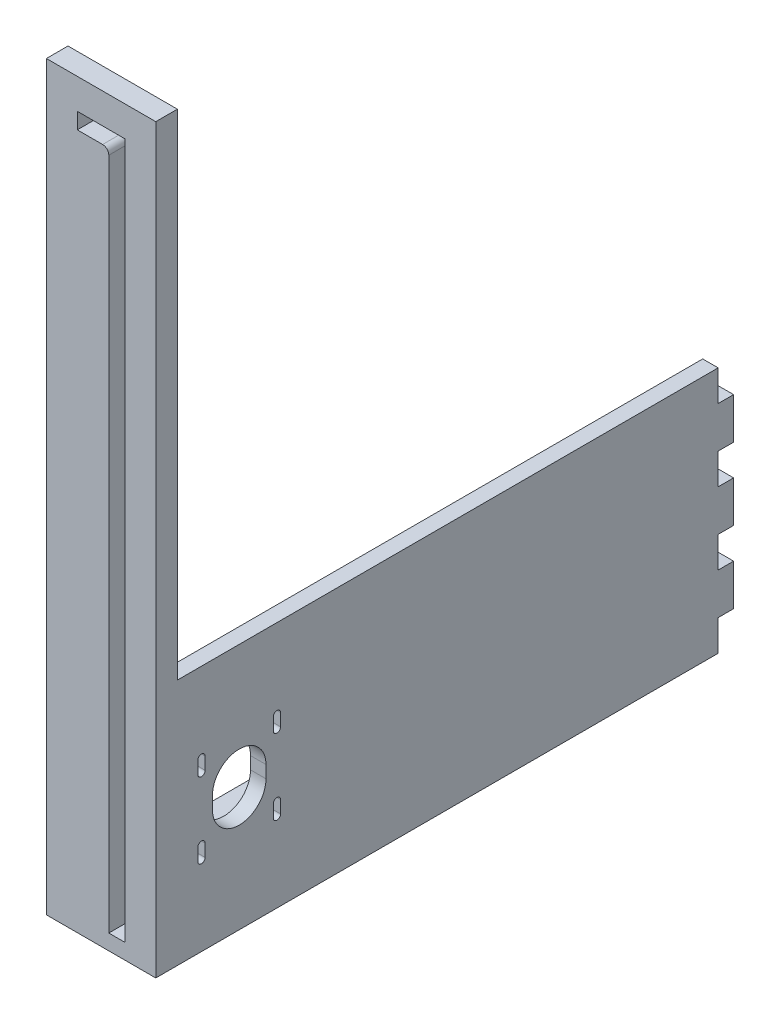
from build123d import *

# Parameters (mm, degrees)
SKETCH1_W           = 44.958
SKETCH1_H           = 304.8
BOSS_EXTRUDE1_DEPTH = 8.89
SKETCH2_W           = 8.89
SKETCH2_H           = 101.6
BOSS_EXTRUDE2_DEPTH = 6.35
SKETCH3_W           = 222.25
SKETCH3_H           = 6.35
BOSS_EXTRUDE3_DEPTH = 38.608


with BuildPart() as part:
    # Sketch1 → Boss-Extrude1 (new body)
    with BuildSketch(Plane.XY):
        with Locations((-6.477, 3.048)):
            Rectangle(SKETCH1_W, SKETCH1_H)
        with BuildLine():
            Line((-3.302, 133.858), (-3.302, -143.002))
            Line((-3.302, -143.002), (3.302, -143.002))
            Line((3.302, -143.002), (3.302, 143.002))
            Line((3.302, 143.002), (-16.256, 143.002))
            Line((-16.256, 143.002), (-16.256, 136.398))
            Line((-16.256, 136.398), (-5.842, 136.398))
            ThreePointArc((-5.842, 136.398), (-4.045948776, 135.654051224), (-3.302, 133.858))
        make_face(mode=Mode.SUBTRACT)
    extrude(amount=BOSS_EXTRUDE1_DEPTH)

    # Sketch2 → Boss-Extrude2 (add)
    with BuildSketch(Plane(origin=(16.002, 0, 0), x_dir=(0, 0, -1), z_dir=(1, 0, 0))):
        Polygon((222.25, -60.452), (222.25, -47.752), (0, -47.752), (0, -149.352), (222.25, -149.352), (222.25, -136.652), (228.6, -136.652), (228.6, -119.718666667), (222.25, -119.718666667), (222.25, -107.018666667), (228.6, -107.018666667), (228.6, -90.085333333), (222.25, -90.085333333), (222.25, -77.385333333), (228.6, -77.385333333), (228.6, -60.452), align=None)
        with BuildLine():
            ThreePointArc((11.4, -116.592), (9.9, -118.092), (8.4, -116.592))
            Line((8.4, -116.592), (8.4, -111.512))
            ThreePointArc((8.4, -111.512), (9.9, -110.012), (11.4, -111.512))
            Line((11.4, -111.512), (11.4, -116.592))
        make_face(mode=Mode.SUBTRACT)
        with BuildLine():
            Line((42.4, -111.512), (42.4, -116.592))
            ThreePointArc((42.4, -116.592), (40.9, -118.092), (39.4, -116.592))
            Line((39.4, -116.592), (39.4, -111.512))
            ThreePointArc((39.4, -111.512), (40.9, -110.012), (42.4, -111.512))
        make_face(mode=Mode.SUBTRACT)
        with BuildLine():
            ThreePointArc((36.4, -101.092), (25.4, -112.092), (14.4, -101.092))
            Line((14.4, -101.092), (14.4, -96.012))
            ThreePointArc((14.4, -96.012), (25.4, -85.012), (36.4, -96.012))
            Line((36.4, -96.012), (36.4, -101.092))
        make_face(mode=Mode.SUBTRACT)
        with BuildLine():
            ThreePointArc((11.4, -85.592), (9.9, -87.092), (8.4, -85.592))
            Line((8.4, -85.592), (8.4, -80.512))
            ThreePointArc((8.4, -80.512), (9.9, -79.012), (11.4, -80.512))
            Line((11.4, -80.512), (11.4, -85.592))
        make_face(mode=Mode.SUBTRACT)
        with BuildLine():
            ThreePointArc((42.4, -85.592), (40.9, -87.092), (39.4, -85.592))
            Line((39.4, -85.592), (39.4, -80.512))
            ThreePointArc((39.4, -80.512), (40.9, -79.012), (42.4, -80.512))
            Line((42.4, -80.512), (42.4, -85.592))
        make_face(mode=Mode.SUBTRACT)
        with Locations((-4.445, -98.552)):
            Rectangle(SKETCH2_W, SKETCH2_H)
    extrude(amount=-BOSS_EXTRUDE2_DEPTH)

    # Sketch3 → Boss-Extrude3 (add)
    with BuildSketch(Plane.ZY.offset(-9.652)):
        with Locations((-111.125, -146.177)):
            Rectangle(SKETCH3_W, SKETCH3_H)
    extrude(amount=BOSS_EXTRUDE3_DEPTH)


solid = part.part
